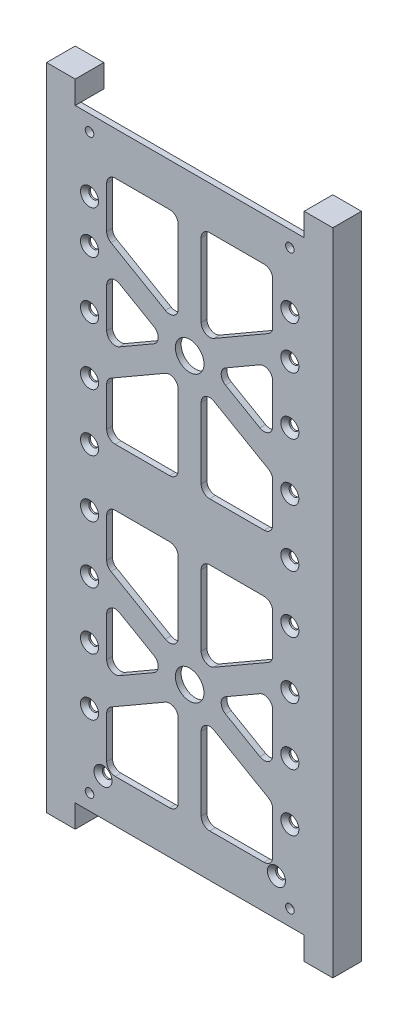
from build123d import *

# Parameters (mm, degrees)
SKETCH1_W                                      = 88
SKETCH1_H                                      = 211
BOSS_EXTRUDE1_DEPTH                            = 2
CUT_EXTRUDE2_DEPTH                             = 2
SKETCH4_R                                      = 5
CUT_EXTRUDE3_DEPTH                             = 3
FILLET2_R                                      = 3
SKETCH5_R                                      = 1.5
CUT_EXTRUDE4_DEPTH                             = 3
BOSS_EXTRUDE2_DEPTH                            = 10
CUT_EXTRUDE5_DEPTH                             = 8
CSK_FOR_M3_FLAT_HEAD_MACHINE_SCREW1_AT_2_COUNT = 2
CSK_FOR_M3_FLAT_HEAD_MACHINE_SCREW1_AT_2_PITCH = 15
CSK_FOR_M3_FLAT_HEAD_MACHINE_SCREW1_AT_3_COUNT = 2
CSK_FOR_M3_FLAT_HEAD_MACHINE_SCREW1_AT_3_PITCH = 35
CSK_FOR_M3_FLAT_HEAD_MACHINE_SCREW1_AT_4_COUNT = 2
CSK_FOR_M3_FLAT_HEAD_MACHINE_SCREW1_AT_4_PITCH = 55
CSK_FOR_M3_FLAT_HEAD_MACHINE_SCREW1_AT_5_COUNT = 2
CSK_FOR_M3_FLAT_HEAD_MACHINE_SCREW1_AT_5_PITCH = 75
CSK_FOR_M3_FLAT_HEAD_MACHINE_SCREW1_AT_6_COUNT = 2
CSK_FOR_M3_FLAT_HEAD_MACHINE_SCREW1_AT_6_PITCH = 95
CSK_FOR_M3_FLAT_HEAD_MACHINE_SCREW1_AT_7_COUNT = 2
CSK_FOR_M3_FLAT_HEAD_MACHINE_SCREW1_AT_7_PITCH = 115
CSK_FOR_M3_FLAT_HEAD_MACHINE_SCREW1_AT_8_COUNT = 2
CSK_FOR_M3_FLAT_HEAD_MACHINE_SCREW1_AT_8_PITCH = 135
CSK_FOR_M3_FLAT_HEAD_MACHINE_SCREW1_AT_9_COUNT = 2
CSK_FOR_M3_FLAT_HEAD_MACHINE_SCREW1_AT_9_PITCH = 155
CSK_FOR_M3_FLAT_HEAD_MACHINE_SCREW1_AT_1_COUNT = 2
CSK_FOR_M3_FLAT_HEAD_MACHINE_SCREW1_AT_1_PITCH = 173.063832154
SKETCH58_R                                     = 1.665
CUT_EXTRUDE9_DEPTH                             = 1.6
SKETCH59_R                                     = 2
CUT_EXTRUDE10_DEPTH                            = 10


with BuildPart() as part:
    # Sketch1 → Boss-Extrude1 (new body)
    with BuildSketch(Plane.XY):
        with Locations((44, 105.5)):
            Rectangle(SKETCH1_W, SKETCH1_H)
    extrude(amount=BOSS_EXTRUDE1_DEPTH)

    # Sketch3 → Cut-Extrude2 (cut)
    with BuildSketch(Plane.XY.offset(2)):
        Polygon((73, 115.5), (73, 133.88804004), (48, 148.32179677), (48, 115.5), align=None)
        Polygon((40, 148.32179677), (15, 133.88804004), (15, 115.5), (40, 115.5), align=None)
        Polygon((36, 155.25), (15, 167.374355653), (15, 143.125644347), align=None)
        Polygon((73, 143.125644347), (73, 167.374355653), (52, 155.25), align=None)
        Polygon((73, 196), (48, 196), (48, 162.17820323), (73, 176.61195996), align=None)
        Polygon((40, 196), (15, 196), (15, 176.61195996), (40, 162.17820323), align=None)
    cut_extrude2 = extrude(amount=-CUT_EXTRUDE2_DEPTH, mode=Mode.SUBTRACT)

    # Sketch4 → Cut-Extrude3 (cut, through all)
    with BuildSketch(Plane.XY.offset(2)):
        with Locations((44, 155.25)):
            Circle(SKETCH4_R)
    cut_extrude3 = extrude(amount=-CUT_EXTRUDE3_DEPTH, mode=Mode.SUBTRACT)

    # Mirror2: Cut-Extrude2, Cut-Extrude3 across plane
    add(cut_extrude2.mirror(Plane(origin=(0, 105.5, 0), x_dir=(0, 0, 1), z_dir=(0, -1, 0))), mode=Mode.SUBTRACT)
    add(cut_extrude3.mirror(Plane(origin=(0, 105.5, 0), x_dir=(0, 0, 1), z_dir=(0, -1, 0))), mode=Mode.SUBTRACT)

    # Fillet2
    fillet2_edges = [part.edges().sort_by_distance(p)[0] for p in [
        (36, 55.75, 1),
        (15, 43.625644347, 1),
        (15, 67.874355653, 1),
        (40, 95.5, 1),
        (40, 62.67820323, 1),
        (15, 77.11195996, 1),
        (15, 95.5, 1),
        (48, 48.82179677, 1),
        (73, 34.38804004, 1),
        (73, 15, 1),
        (48, 15, 1),
        (73, 43.625644347, 1),
        (52, 55.75, 1),
        (73, 67.874355653, 1),
        (15, 15, 1),
        (15, 34.38804004, 1),
        (40, 48.82179677, 1),
        (40, 15, 1),
        (73, 77.11195996, 1),
        (48, 62.67820323, 1),
        (48, 95.5, 1),
        (73, 95.5, 1),
        (15, 167.374355653, 1),
        (36, 155.25, 1),
        (15, 143.125644347, 1),
        (40, 148.32179677, 1),
        (40, 115.5, 1),
        (15, 115.5, 1),
        (15, 133.88804004, 1),
        (73, 176.61195996, 1),
        (48, 162.17820323, 1),
        (48, 196, 1),
        (73, 196, 1),
        (52, 155.25, 1),
        (73, 167.374355653, 1),
        (73, 143.125644347, 1),
        (15, 176.61195996, 1),
        (15, 196, 1),
        (40, 196, 1),
        (40, 162.17820323, 1),
        (48, 148.32179677, 1),
        (73, 133.88804004, 1),
        (73, 115.5, 1),
        (48, 115.5, 1),
    ]]
    fillet(fillet2_edges, radius=FILLET2_R)

    # Sketch5 → Cut-Extrude4 (cut, through all)
    with BuildSketch(Plane.XY.offset(2)):
        with Locations((9, 205.5)):
            Circle(SKETCH5_R)
        with Locations((79, 205.5)):
            Circle(SKETCH5_R)
        with Locations((9, 5.5)):
            Circle(SKETCH5_R)
        with Locations((79, 5.5)):
            Circle(SKETCH5_R)
    extrude(amount=-CUT_EXTRUDE4_DEPTH, mode=Mode.SUBTRACT)

    # Sketch7 → Boss-Extrude2 (add)
    with BuildSketch(Plane.XY.offset(2)):
        Polygon((94, 219), (84, 219), (84, 211), (88, 211), (88, 0), (84, 0), (84, -8), (94, -8), align=None)
        Polygon((-6, -8), (4, -8), (4, 0), (0, 0), (0, 211), (4, 211), (4, 219), (-6, 219), align=None)
    extrude(amount=-BOSS_EXTRUDE2_DEPTH)

    # Sketch53 → Cut-Extrude5 (cut)
    with BuildSketch(Plane(origin=(0, 0, -8), x_dir=(-1, 0, 0), z_dir=(0, 0, -1))):
        with BuildLine():
            Line((-90, 0), (-88, 0))
            Line((-88, 0), (-88, 211))
            Line((-88, 211), (-90, 211))
            ThreePointArc((-90, 211), (-91.414213562, 210.414213562), (-92, 209))
            Line((-92, 209), (-92, 2))
            ThreePointArc((-92, 2), (-91.414213562, 0.585786438), (-90, 0))
        make_face()
        with BuildLine():
            Line((2, 0), (-4, 0))
            Line((-4, 0), (-4, 211))
            Line((-4, 211), (2, 211))
            ThreePointArc((2, 211), (3.414213562, 210.414213562), (4, 209))
            Line((4, 209), (4, 2))
            ThreePointArc((4, 2), (3.414213562, 0.585786438), (2, 0))
        make_face()
    extrude(amount=-CUT_EXTRUDE5_DEPTH, mode=Mode.SUBTRACT)

    # Sketch56 → CSK for M3 Flat Head Machine Screw1 (revolve, cut)
    with BuildSketch(Plane(origin=(9, 186, 2), x_dir=(0, -1, 0), z_dir=(1, 0, 0))):
        Polygon((0, 0), (0, 11.021463052), (1.7, 10), (1.7, 1.45), (3.15, 0), align=None)
    csk_for_m3_flat_head_machine_screw1 = revolve(axis=Axis((9, 186, 8.35), (0, 0, -1)), mode=Mode.SUBTRACT)

    # CSK for M3 Flat Head Machine Screw1 at 2: CSK for M3 Flat Head Machine Screw1 ×2
    with Locations(*[(0, -i * CSK_FOR_M3_FLAT_HEAD_MACHINE_SCREW1_AT_2_PITCH, 0) for i in range(1, CSK_FOR_M3_FLAT_HEAD_MACHINE_SCREW1_AT_2_COUNT)]):
        add(csk_for_m3_flat_head_machine_screw1, mode=Mode.SUBTRACT)

    # CSK for M3 Flat Head Machine Screw1 at 3: CSK for M3 Flat Head Machine Screw1 ×2
    with Locations(*[(0, -i * CSK_FOR_M3_FLAT_HEAD_MACHINE_SCREW1_AT_3_PITCH, 0) for i in range(1, CSK_FOR_M3_FLAT_HEAD_MACHINE_SCREW1_AT_3_COUNT)]):
        add(csk_for_m3_flat_head_machine_screw1, mode=Mode.SUBTRACT)

    # CSK for M3 Flat Head Machine Screw1 at 4: CSK for M3 Flat Head Machine Screw1 ×2
    with Locations(*[(0, -i * CSK_FOR_M3_FLAT_HEAD_MACHINE_SCREW1_AT_4_PITCH, 0) for i in range(1, CSK_FOR_M3_FLAT_HEAD_MACHINE_SCREW1_AT_4_COUNT)]):
        add(csk_for_m3_flat_head_machine_screw1, mode=Mode.SUBTRACT)

    # CSK for M3 Flat Head Machine Screw1 at 5: CSK for M3 Flat Head Machine Screw1 ×2
    with Locations(*[(0, -i * CSK_FOR_M3_FLAT_HEAD_MACHINE_SCREW1_AT_5_PITCH, 0) for i in range(1, CSK_FOR_M3_FLAT_HEAD_MACHINE_SCREW1_AT_5_COUNT)]):
        add(csk_for_m3_flat_head_machine_screw1, mode=Mode.SUBTRACT)

    # CSK for M3 Flat Head Machine Screw1 at 6: CSK for M3 Flat Head Machine Screw1 ×2
    with Locations(*[(0, -i * CSK_FOR_M3_FLAT_HEAD_MACHINE_SCREW1_AT_6_PITCH, 0) for i in range(1, CSK_FOR_M3_FLAT_HEAD_MACHINE_SCREW1_AT_6_COUNT)]):
        add(csk_for_m3_flat_head_machine_screw1, mode=Mode.SUBTRACT)

    # CSK for M3 Flat Head Machine Screw1 at 7: CSK for M3 Flat Head Machine Screw1 ×2
    with Locations(*[(0, -i * CSK_FOR_M3_FLAT_HEAD_MACHINE_SCREW1_AT_7_PITCH, 0) for i in range(1, CSK_FOR_M3_FLAT_HEAD_MACHINE_SCREW1_AT_7_COUNT)]):
        add(csk_for_m3_flat_head_machine_screw1, mode=Mode.SUBTRACT)

    # CSK for M3 Flat Head Machine Screw1 at 8: CSK for M3 Flat Head Machine Screw1 ×2
    with Locations(*[(0, -i * CSK_FOR_M3_FLAT_HEAD_MACHINE_SCREW1_AT_8_PITCH, 0) for i in range(1, CSK_FOR_M3_FLAT_HEAD_MACHINE_SCREW1_AT_8_COUNT)]):
        add(csk_for_m3_flat_head_machine_screw1, mode=Mode.SUBTRACT)

    # CSK for M3 Flat Head Machine Screw1 at 9: CSK for M3 Flat Head Machine Screw1 ×2
    with Locations(*[(0, -i * CSK_FOR_M3_FLAT_HEAD_MACHINE_SCREW1_AT_9_PITCH, 0) for i in range(1, CSK_FOR_M3_FLAT_HEAD_MACHINE_SCREW1_AT_9_COUNT)]):
        add(csk_for_m3_flat_head_machine_screw1, mode=Mode.SUBTRACT)

    # CSK for M3 Flat Head Machine Screw1 at 1: CSK for M3 Flat Head Machine Screw1 ×2
    with Locations(*[Vector(0.02715761, -0.999631164, 0) * (i * CSK_FOR_M3_FLAT_HEAD_MACHINE_SCREW1_AT_1_PITCH) for i in range(1, CSK_FOR_M3_FLAT_HEAD_MACHINE_SCREW1_AT_1_COUNT)]):
        add(csk_for_m3_flat_head_machine_screw1, mode=Mode.SUBTRACT)

    # Mirror3: CSK for M3 Flat Head Machine Screw1 across plane
    add(csk_for_m3_flat_head_machine_screw1.mirror(Plane.ZY.offset(-44)), mode=Mode.SUBTRACT)

    # Mirror3 copy 1 sketch → Mirror3 copy 1 (revolve, cut)
    with BuildSketch(Plane(origin=(79, 171, 2), x_dir=(0, -1, 0), z_dir=(-1, 0, 0))):
        Polygon((0, 0), (0, -11.021463052), (1.7, -10), (1.7, -1.45), (3.15, 0), align=None)
    revolve(axis=Axis((79, 171, 8.35), (0, 0, 1)), mode=Mode.SUBTRACT)

    # Mirror3 copy 2 sketch → Mirror3 copy 2 (revolve, cut)
    with BuildSketch(Plane(origin=(79, 151, 2), x_dir=(0, -1, 0), z_dir=(-1, 0, 0))):
        Polygon((0, 0), (0, -11.021463052), (1.7, -10), (1.7, -1.45), (3.15, 0), align=None)
    revolve(axis=Axis((79, 151, 8.35), (0, 0, 1)), mode=Mode.SUBTRACT)

    # Mirror3 copy 3 sketch → Mirror3 copy 3 (revolve, cut)
    with BuildSketch(Plane(origin=(79, 131, 2), x_dir=(0, -1, 0), z_dir=(-1, 0, 0))):
        Polygon((0, 0), (0, -11.021463052), (1.7, -10), (1.7, -1.45), (3.15, 0), align=None)
    revolve(axis=Axis((79, 131, 8.35), (0, 0, 1)), mode=Mode.SUBTRACT)

    # Mirror3 copy 4 sketch → Mirror3 copy 4 (revolve, cut)
    with BuildSketch(Plane(origin=(79, 111, 2), x_dir=(0, -1, 0), z_dir=(-1, 0, 0))):
        Polygon((0, 0), (0, -11.021463052), (1.7, -10), (1.7, -1.45), (3.15, 0), align=None)
    revolve(axis=Axis((79, 111, 8.35), (0, 0, 1)), mode=Mode.SUBTRACT)

    # Mirror3 copy 5 sketch → Mirror3 copy 5 (revolve, cut)
    with BuildSketch(Plane(origin=(79, 91, 2), x_dir=(0, -1, 0), z_dir=(-1, 0, 0))):
        Polygon((0, 0), (0, -11.021463052), (1.7, -10), (1.7, -1.45), (3.15, 0), align=None)
    revolve(axis=Axis((79, 91, 8.35), (0, 0, 1)), mode=Mode.SUBTRACT)

    # Mirror3 copy 6 sketch → Mirror3 copy 6 (revolve, cut)
    with BuildSketch(Plane(origin=(79, 71, 2), x_dir=(0, -1, 0), z_dir=(-1, 0, 0))):
        Polygon((0, 0), (0, -11.021463052), (1.7, -10), (1.7, -1.45), (3.15, 0), align=None)
    revolve(axis=Axis((79, 71, 8.35), (0, 0, 1)), mode=Mode.SUBTRACT)

    # Mirror3 copy 7 sketch → Mirror3 copy 7 (revolve, cut)
    with BuildSketch(Plane(origin=(79, 51, 2), x_dir=(0, -1, 0), z_dir=(-1, 0, 0))):
        Polygon((0, 0), (0, -11.021463052), (1.7, -10), (1.7, -1.45), (3.15, 0), align=None)
    revolve(axis=Axis((79, 51, 8.35), (0, 0, 1)), mode=Mode.SUBTRACT)

    # Mirror3 copy 8 sketch → Mirror3 copy 8 (revolve, cut)
    with BuildSketch(Plane(origin=(79, 31, 2), x_dir=(0, -1, 0), z_dir=(-1, 0, 0))):
        Polygon((0, 0), (0, -11.021463052), (1.7, -10), (1.7, -1.45), (3.15, 0), align=None)
    revolve(axis=Axis((79, 31, 8.35), (0, 0, 1)), mode=Mode.SUBTRACT)

    # Mirror3 copy 9 sketch → Mirror3 copy 9 (revolve, cut)
    with BuildSketch(Plane(origin=(74.3, 13, 2), x_dir=(0, -1, 0), z_dir=(-1, 0, 0))):
        Polygon((0, 0), (0, -11.021463052), (1.7, -10), (1.7, -1.45), (3.15, 0), align=None)
    revolve(axis=Axis((74.3, 13, 8.35), (0, 0, 1)), mode=Mode.SUBTRACT)

    # Sketch58 → Cut-Extrude9 (cut)
    with BuildSketch(Plane(origin=(0, 0, 0), x_dir=(-1, 0, 0), z_dir=(0, 0, -1))):
        with Locations((-0.7, 13)):
            Circle(SKETCH58_R)
    cut_extrude9 = extrude(amount=-CUT_EXTRUDE9_DEPTH, mode=Mode.SUBTRACT)

    # Mirror4: Cut-Extrude9 across plane
    add(cut_extrude9.mirror(Plane(origin=(44, 0, 0), x_dir=(0, 0, 1), z_dir=(1, 0, 0))), mode=Mode.SUBTRACT)

    # Sketch59 → Cut-Extrude10 (cut)
    with BuildSketch(Plane(origin=(0, -8, 0), x_dir=(-1, 0, 0), z_dir=(0, -1, 0))):
        with Locations((1, 3)):
            Circle(SKETCH59_R)
    cut_extrude10 = extrude(amount=-CUT_EXTRUDE10_DEPTH, mode=Mode.SUBTRACT)

    # Mirror5: Cut-Extrude10 across plane
    add(cut_extrude10.mirror(Plane.ZY.offset(-44)), mode=Mode.SUBTRACT)


solid = part.part
